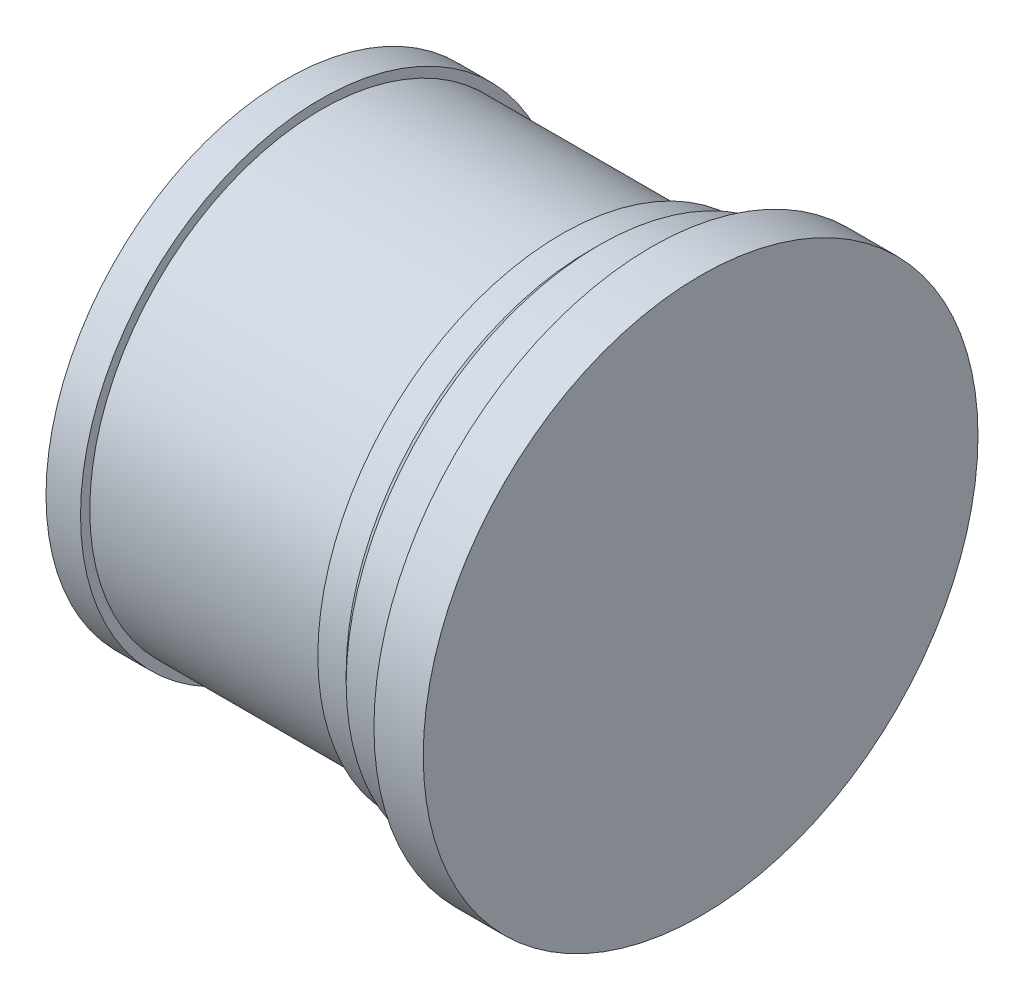
from build123d import *


with BuildPart() as part:
    # Sketch1 → Revolve1 (revolve)
    with BuildSketch(Plane.XY):
        Polygon((0, 0), (33.6, 0), (33.6, 22.5), (29.6, 22.5), (29.6, 19.75), (28.85, 19.75), (28.85, 20.5), (25.35, 20.5), (24.6, 19.75), (22.3, 19.75), (22.3, 18.75), (2.8, 18.75), (2.8, 19.5), (0, 19.5), align=None)
    revolve(axis=Axis((0, 0, 0), (1, 0, 0)))


solid = part.part
